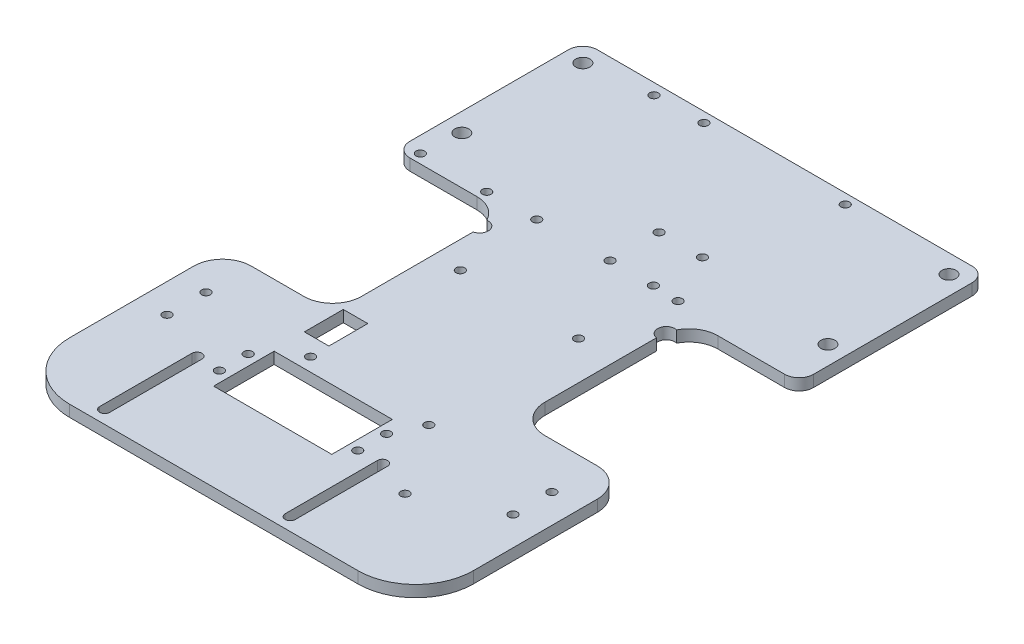
from build123d import *

# Parameters (mm, degrees)
BOSS_EXTRUDE1_DEPTH     = 4
SKETCH2_R               = 2.45
SKETCH2_R_2             = 1.5
SKETCH2_W               = 41
SKETCH2_H               = 21
SKETCH2_W_2             = 8.5
SKETCH2_H_2             = 13.5
CUT_EXTRUDE1_DEPTH      = 1
CUT_EXTRUDE1_DEPTH_BACK = 5
CUT_EXTRUDE2_DEPTH      = 1
CUT_EXTRUDE2_DEPTH_BACK = 5
FILLET1_R               = 10
FILLET2_R               = 5


with BuildPart() as part:
    # Sketch1 → Boss-Extrude1 (new body)
    with BuildSketch(Plane(origin=(0, 0, 0), x_dir=(1, 0, 0), z_dir=(0, 1, 0))):
        with BuildLine():
            Line((-120, 0), (-135, 0))
            ThreePointArc((-135, 0), (-138.535533906, -1.464466094), (-140, -5))
            Line((-140, -5), (-140, -20))
            Line((-140, -20), (-140, -178))
            ThreePointArc((-140, -178), (-134.142135624, -192.142135624), (-120, -198))
            Line((-120, -198), (-20, -198))
            ThreePointArc((-20, -198), (-5.857864376, -192.142135624), (0, -178))
            Line((0, -178), (0, -20))
            Line((0, -20), (0, -5))
            ThreePointArc((0, -5), (-1.464466094, -1.464466094), (-5, 0))
            Line((-5, 0), (-20, 0))
            Line((-20, 0), (-120, 0))
        make_face()
    extrude(amount=BOSS_EXTRUDE1_DEPTH)

    # Sketch2 → Cut-Extrude1 (cut, two sides)
    with BuildSketch(Plane(origin=(0, 4, 0), x_dir=(1, 0, 0), z_dir=(0, 1, 0))) as cut_extrude1_sk:
        with Locations((-6.5, -6.5)):
            Circle(SKETCH2_R)
        with Locations((-6.5, -48.5)):
            Circle(SKETCH2_R)
        with Locations((-133.5, -48.5)):
            Circle(SKETCH2_R)
        with Locations((-133.5, -6.5)):
            Circle(SKETCH2_R)
        with Locations((-130, -140.75)):
            Circle(SKETCH2_R_2)
        with Locations((-130, -154.25)):
            Circle(SKETCH2_R_2)
        with Locations((-10, -154.25)):
            Circle(SKETCH2_R_2)
        with Locations((-10, -140.75)):
            Circle(SKETCH2_R_2)
        with Locations((-69.414803196, -44.13296789)):
            Circle(SKETCH2_R_2)
        with Locations((-104.151064992, -151.948209631)):
            Circle(SKETCH2_R_2)
        with Locations((-104.151064992, -161.948209631)):
            Circle(SKETCH2_R_2)
        with Locations((-56.151064992, -161.948209631)):
            Circle(SKETCH2_R_2)
        with Locations((-54.414803196, -44.13296789)):
            Circle(SKETCH2_R_2)
        with Locations((-54.414803196, -61.13296789)):
            Circle(SKETCH2_R_2)
        with Locations((-69.414803196, -61.13296789)):
            Circle(SKETCH2_R_2)
        with Locations((-51.500110177, -90.016074618)):
            Circle(SKETCH2_R_2)
        with Locations((-51.500110177, -141.948209631)):
            Circle(SKETCH2_R_2)
        with Locations((-56.151064992, -151.948209631)):
            Circle(SKETCH2_R_2)
        with Locations((-92.500110177, -141.948209631)):
            Circle(SKETCH2_R_2)
        with Locations((-92.500110177, -90.016074618)):
            Circle(SKETCH2_R_2)
        with Locations((-45.5, -61.5)):
            Circle(SKETCH2_R_2)
        with Locations((-45.5, -3.5)):
            Circle(SKETCH2_R_2)
        with Locations((-94.5, -3.5)):
            Circle(SKETCH2_R_2)
        with Locations((-94.5, -61.5)):
            Circle(SKETCH2_R_2)
        with Locations((-111.497219826, -3.864602307)):
            Circle(SKETCH2_R_2)
        with Locations((-111.497219826, -61.864602307)):
            Circle(SKETCH2_R_2)
        with Locations((-134.497219826, -61.864602307)):
            Circle(SKETCH2_R_2)
        with Locations((-34.958630408, -166.730986033)):
            Circle(SKETCH2_R_2)
        with BuildLine():
            Line((-110.626547642, -161.5), (-110.626547642, -193.5))
            ThreePointArc((-110.626547642, -193.5), (-112.376547642, -195.25), (-114.126547642, -193.5))
            Line((-114.126547642, -193.5), (-114.126547642, -161.5))
            ThreePointArc((-114.126547642, -161.5), (-112.376547642, -159.75), (-110.626547642, -161.5))
        make_face()
        with Locations((-79.990616651, -157.105574446)):
            Rectangle(SKETCH2_W, SKETCH2_H)
        with Locations((-96.791094648, -128.818094274)):
            Rectangle(SKETCH2_W_2, SKETCH2_H_2)
        with BuildLine():
            Line((-46.25, -161.5), (-46.25, -193.5))
            ThreePointArc((-46.25, -193.5), (-48, -195.25), (-49.75, -193.5))
            Line((-49.75, -193.5), (-49.75, -161.5))
            ThreePointArc((-49.75, -161.5), (-48, -159.75), (-46.25, -161.5))
        make_face()
    extrude(amount=CUT_EXTRUDE1_DEPTH, mode=Mode.SUBTRACT)
    extrude(cut_extrude1_sk.sketch, amount=-CUT_EXTRUDE1_DEPTH_BACK, mode=Mode.SUBTRACT)

    # Sketch3 → Cut-Extrude2 (cut, two sides)
    with BuildSketch(Plane(origin=(0, 0, 0), x_dir=(-1, 0, 0), z_dir=(0, -1, 0))) as cut_extrude2_sk:
        with BuildLine():
            Line((0, -65), (28.208630408, -65))
            ThreePointArc((28.208630408, -65), (33.396116586, -66.450731777), (37.078472556, -70.382002569))
            ThreePointArc((37.078472556, -70.382002569), (40.706583622, -72.737954213), (38.208630408, -76.269799027))
            Line((38.208630408, -76.269799027), (38.208630408, -115))
            ThreePointArc((38.208630408, -115), (35.27969822, -122.071067812), (28.208630408, -125))
            Line((28.208630408, -125), (0, -125))
            Line((0, -125), (0, -65))
        make_face()
        with BuildLine():
            Line((140, -65), (140, -125))
            Line((140, -125), (111.791369592, -125))
            ThreePointArc((111.791369592, -125), (104.72030178, -122.071067812), (101.791369592, -115))
            Line((101.791369592, -115), (101.791369592, -76.269799027))
            ThreePointArc((101.791369592, -76.269799027), (99.527050592, -72.782800115), (102.921527444, -70.382002569))
            ThreePointArc((102.921527444, -70.382002569), (106.603883414, -66.450731777), (111.791369592, -65))
            Line((111.791369592, -65), (140, -65))
        make_face()
    extrude(amount=CUT_EXTRUDE2_DEPTH, mode=Mode.SUBTRACT)
    extrude(cut_extrude2_sk.sketch, amount=-CUT_EXTRUDE2_DEPTH_BACK, mode=Mode.SUBTRACT)

    # Fillet1
    fillet1_edges = [part.edges().sort_by_distance(p)[0] for p in [
        (0, 2, 125),
        (-140, 2, 125),
    ]]
    fillet(fillet1_edges, radius=FILLET1_R)

    # Fillet2
    fillet2_edges = [part.edges().sort_by_distance(p)[0] for p in [
        (-140, 2, 65),
        (0, 2, 65),
    ]]
    fillet(fillet2_edges, radius=FILLET2_R)


solid = part.part
